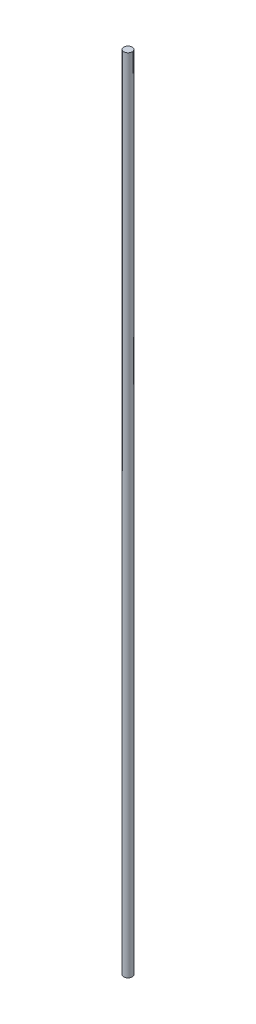
from build123d import *

# Parameters (mm, degrees)
SKETCH1_R           = 1.5875
BOSS_EXTRUDE1_DEPTH = 304.8


with BuildPart() as part:
    # Sketch1 → Boss-Extrude1 (new body)
    with BuildSketch(Plane(origin=(0, 0, 0), x_dir=(1, 0, 0), z_dir=(0, 1, 0))):
        Circle(SKETCH1_R)
    extrude(amount=BOSS_EXTRUDE1_DEPTH)


solid = part.part
